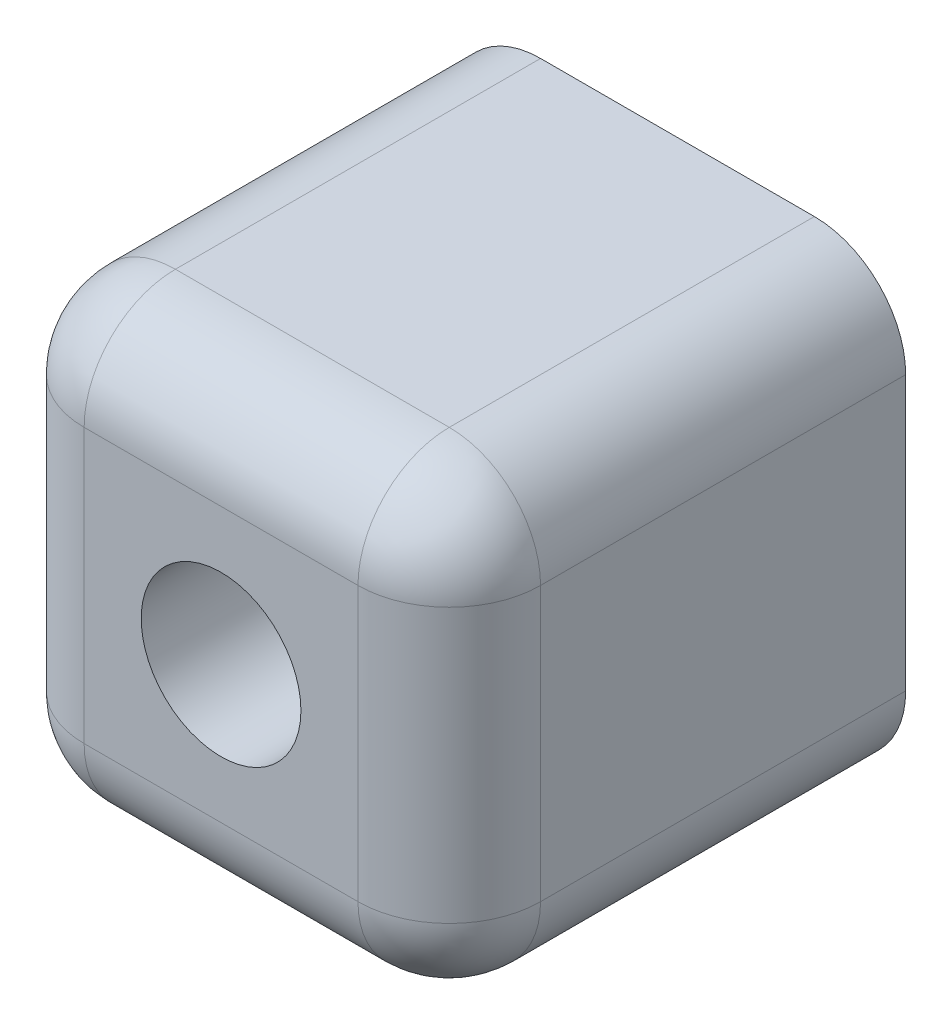
from build123d import *

# Parameters (mm, degrees)
SKETCH1_W           = 10
SKETCH1_H           = 10
BOSS_EXTRUDE1_DEPTH = 10
SKETCH2_R           = 1.75
CUT_EXTRUDE1_DEPTH  = 11
SKETCH3_R           = 2.05
CUT_EXTRUDE2_DEPTH  = 5
FILLET1_R           = 2
FILLET2_R           = 2


with BuildPart() as part:
    # Sketch1 → Boss-Extrude1 (new body)
    with BuildSketch(Plane.XY):
        with Locations((5, 5)):
            Rectangle(SKETCH1_W, SKETCH1_H)
    extrude(amount=BOSS_EXTRUDE1_DEPTH)

    # Sketch2 → Cut-Extrude1 (cut, through all)
    with BuildSketch(Plane.XY.offset(10)):
        with Locations((5, 5)):
            Circle(SKETCH2_R)
    extrude(amount=-CUT_EXTRUDE1_DEPTH, mode=Mode.SUBTRACT)

    # Sketch3 → Cut-Extrude2 (cut)
    with BuildSketch(Plane(origin=(0, 0, 0), x_dir=(-1, 0, 0), z_dir=(0, 0, -1))):
        with Locations((-5, 5)):
            Circle(SKETCH3_R)
    extrude(amount=-CUT_EXTRUDE2_DEPTH, mode=Mode.SUBTRACT)

    # Fillet1
    fillet1_edges = [part.edges().sort_by_distance(p)[0] for p in [
        (0, 10, 5),
        (10, 10, 5),
        (10, 0, 5),
        (0, 0, 5),
    ]]
    fillet(fillet1_edges, radius=FILLET1_R)

    # Fillet2
    fillet2_edges = [part.edges().sort_by_distance(p)[0] for p in [
        (5, 10, 10),
        (10, 5, 10),
        (0, 5, 10),
        (5, 0, 10),
        (9.414213562, 0.585786438, 10),
        (0.585786438, 0.585786438, 10),
        (0.585786438, 9.414213562, 10),
        (9.414213562, 9.414213562, 10),
    ]]
    fillet(fillet2_edges, radius=FILLET2_R)


solid = part.part
